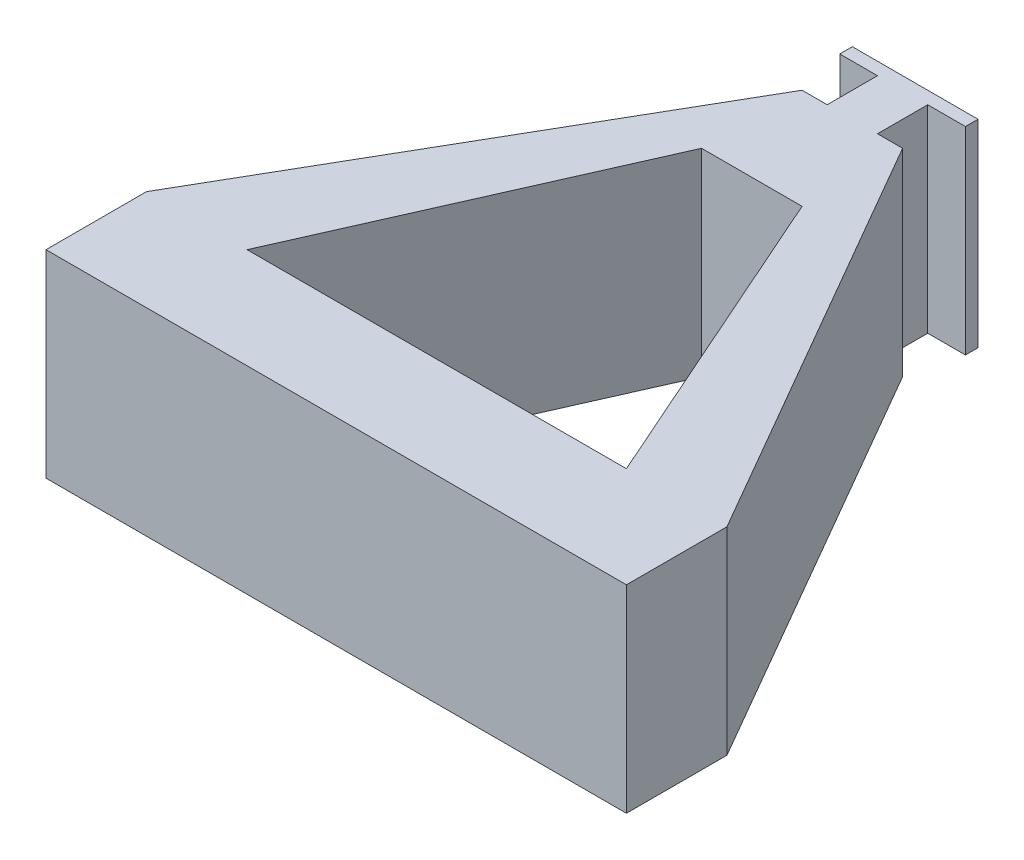
from build123d import *

# Parameters (mm, degrees)
BOSS_EXTRUDE1_DEPTH = 100


with BuildPart() as part:
    # Sketch1 → Boss-Extrude1 (new body)
    with BuildSketch(Plane(origin=(0, 0, 0), x_dir=(1, 0, 0), z_dir=(0, 1, 0))):
        Polygon((-146.64355653, -95.4), (146.64355653, -95.4), (146.64355653, -44.6), (25.4, 165.4), (12.7, 165.4), (12.7, 190.8), (31.75, 190.8), (31.75, 197.15), (-31.75, 197.15), (-31.75, 190.8), (-12.7, 190.8), (-12.7, 165.4), (-25.4, 165.4), (-146.64355653, -44.6), align=None)
        Polygon((25.4, 114.6), (95.84355653, -44.6), (-95.84355653, -44.6), (-25.4, 114.6), align=None, mode=Mode.SUBTRACT)
    extrude(amount=BOSS_EXTRUDE1_DEPTH)


solid = part.part
